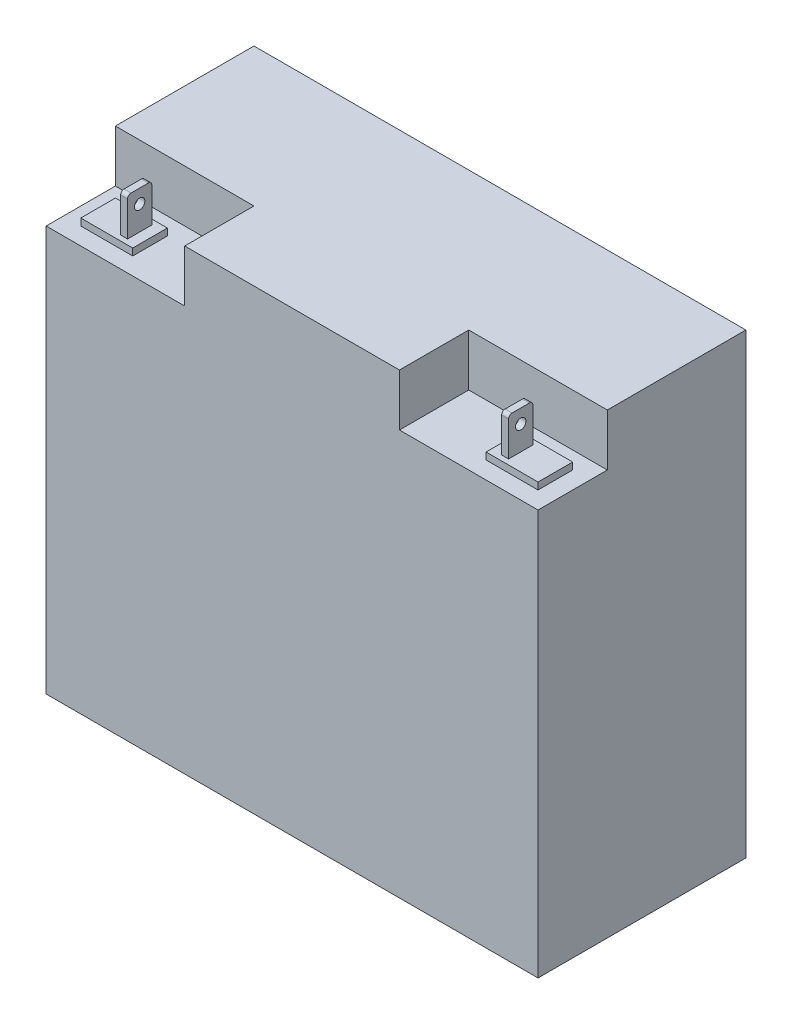
from build123d import *

# Parameters (mm, degrees)
SKETCH1_W           = 180.34
SKETCH1_H           = 167.64
CASE_2_DEPTH        = 38.1
SKETCH2_W           = 50.8
SKETCH2_H           = 25.4
TOP_HOLE_DEPTH      = 19.05
SKETCH3_W           = 19.05
SKETCH3_H           = 12.7
BOSS_EXTRUDE2_DEPTH = 2.54
SKETCH4_W           = 2.54
SKETCH4_H           = 8.89
BOSS_EXTRUDE3_DEPTH = 13.97
SKETCH5_R           = 1.905
CUT_EXTRUDE2_DEPTH  = 2.54
SKETCH6_W           = 19.05
SKETCH6_H           = 12.7
BOSS_EXTRUDE4_DEPTH = 2.54


with BuildPart() as part:
    # Sketch1 → case 2 (new body, symmetric)
    with BuildSketch(Plane.XY):
        with Locations((90.17, 83.82)):
            Rectangle(SKETCH1_W, SKETCH1_H)
    extrude(amount=CASE_2_DEPTH, both=True)

    # Sketch2 → top hole (cut)
    with BuildSketch(Plane(origin=(0, 167.64, 0), x_dir=(1, 0, 0), z_dir=(0, 1, 0))):
        with Locations((25.4, -25.4)):
            Rectangle(SKETCH2_W, SKETCH2_H)
        with Locations((154.94, -25.4)):
            Rectangle(SKETCH2_W, SKETCH2_H)
    extrude(amount=-TOP_HOLE_DEPTH, mode=Mode.SUBTRACT)

    # Sketch3 → Boss-Extrude2 (add)
    with BuildSketch(Plane(origin=(0, 148.59, 0), x_dir=(1, 0, 0), z_dir=(0, 1, 0))):
        with Locations((15.875, -25.4)):
            Rectangle(SKETCH3_W, SKETCH3_H)
    extrude(amount=BOSS_EXTRUDE2_DEPTH)

    # Sketch4 → Boss-Extrude3 (add)
    with BuildSketch(Plane(origin=(0, 151.13, 0), x_dir=(1, 0, 0), z_dir=(0, 1, 0))):
        with Locations((20.32, -25.4)):
            Rectangle(SKETCH4_W, SKETCH4_H)
    boss_extrude3 = extrude(amount=BOSS_EXTRUDE3_DEPTH)

    # Sketch5 → Cut-Extrude2 (cut)
    with BuildSketch(Plane(origin=(21.59, 0, 0), x_dir=(0, 0, -1), z_dir=(1, 0, 0))):
        with BuildLine():
            ThreePointArc((-22.225, 165.1), (-21.326974388, 164.728025612), (-20.955, 163.83))
            Line((-20.955, 163.83), (-20.955, 165.1))
            Line((-20.955, 165.1), (-22.225, 165.1))
        make_face()
        with BuildLine():
            Line((-29.845, 165.1), (-29.845, 163.83))
            ThreePointArc((-29.845, 163.83), (-29.473025612, 164.728025612), (-28.575, 165.1))
            Line((-28.575, 165.1), (-29.845, 165.1))
        make_face()
        with Locations((-25.4, 160.02)):
            Circle(SKETCH5_R)
    cut_extrude2 = extrude(amount=-CUT_EXTRUDE2_DEPTH, mode=Mode.SUBTRACT)

    # Sketch6 → Boss-Extrude4 (add)
    with BuildSketch(Plane(origin=(0, 148.59, 0), x_dir=(1, 0, 0), z_dir=(0, 1, 0))):
        with Locations((164.465, -25.4)):
            Rectangle(SKETCH6_W, SKETCH6_H)
    extrude(amount=BOSS_EXTRUDE4_DEPTH)

    # Mirror1: Boss-Extrude3, Cut-Extrude2 across plane
    add(boss_extrude3.mirror(Plane(origin=(90.17, 0, 0), x_dir=(0, 0, 1), z_dir=(1, 0, 0))))
    add(cut_extrude2.mirror(Plane(origin=(90.17, 0, 0), x_dir=(0, 0, 1), z_dir=(1, 0, 0))), mode=Mode.SUBTRACT)


solid = part.part
